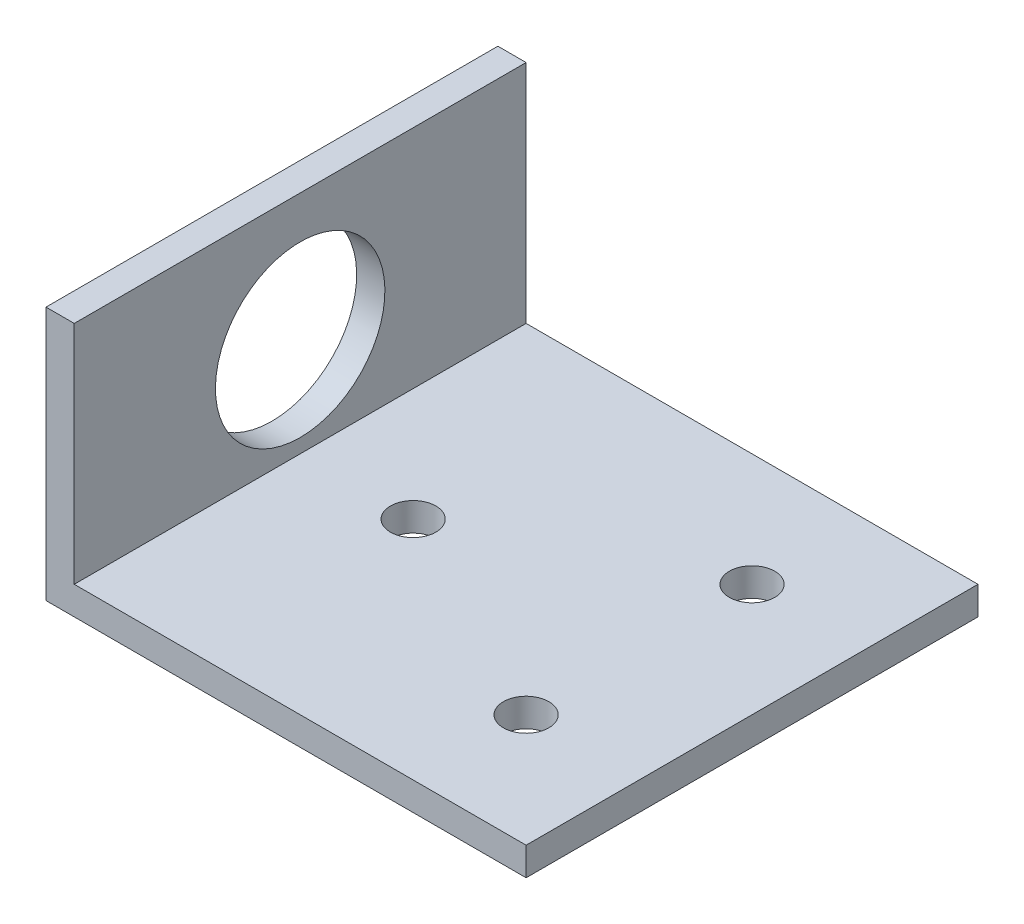
from build123d import *

# Parameters (mm, degrees)
BOSS_EXTRUDE1_DEPTH = 50.8
SKETCH2_R           = 9.525
SKETCH2_W           = 50.8
SKETCH2_H           = 22.225
CUT_EXTRUDE1_DEPTH  = 50.8
SKETCH3_R           = 2.5527
CUT_EXTRUDE2_DEPTH  = 50.8


with BuildPart() as part:
    # Sketch1 → Boss-Extrude1 (new body)
    with BuildSketch(Plane.XY):
        Polygon((3.175, 50.8), (0, 50.8), (0, 0), (3.175, 0), (53.975, 0), (53.975, 3.175), (3.175, 3.175), align=None)
    extrude(amount=BOSS_EXTRUDE1_DEPTH)

    # Sketch2 → Cut-Extrude1 (cut)
    with BuildSketch(Plane.ZY):
        with Locations((25.4, 14.2875)):
            Circle(SKETCH2_R)
        with Locations((25.4, 39.6875)):
            Rectangle(SKETCH2_W, SKETCH2_H)
    extrude(amount=-CUT_EXTRUDE1_DEPTH, mode=Mode.SUBTRACT)

    # Sketch3 → Cut-Extrude2 (cut)
    with BuildSketch(Plane(origin=(0, 0, 0), x_dir=(-1, 0, 0), z_dir=(0, -1, 0))):
        with Locations((-15.875, -25.4)):
            Circle(SKETCH3_R)
        with Locations((-41.275, -38.1)):
            Circle(SKETCH3_R)
        with Locations((-41.275, -12.7)):
            Circle(SKETCH3_R)
    extrude(amount=-CUT_EXTRUDE2_DEPTH, mode=Mode.SUBTRACT)


solid = part.part
